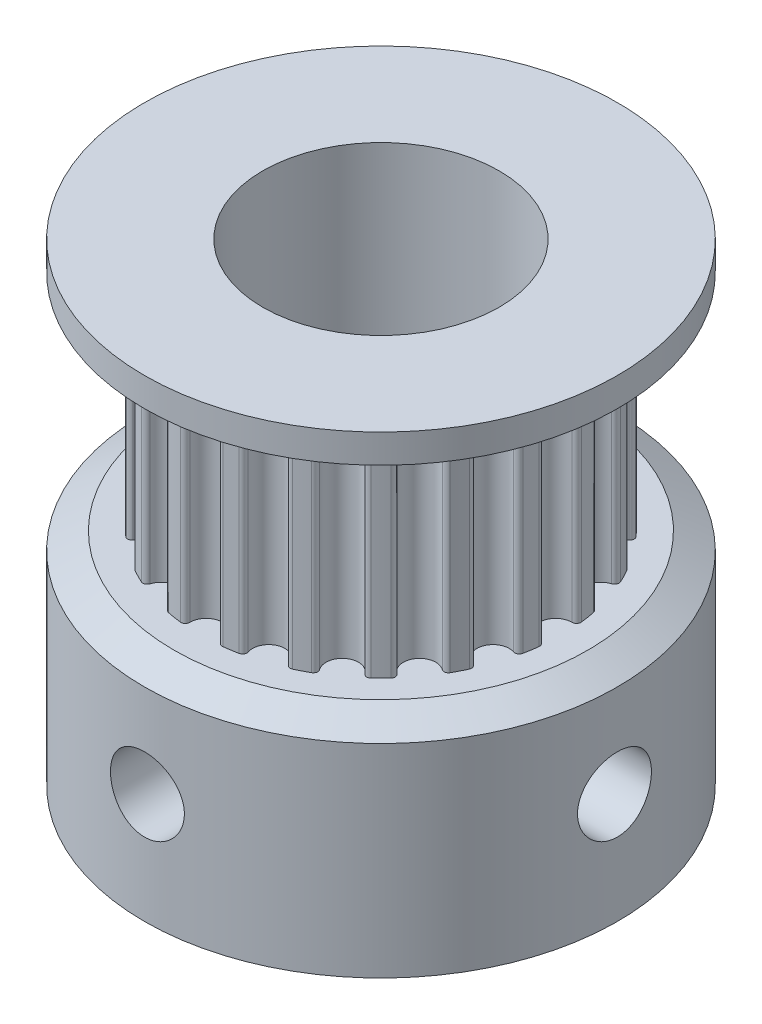
from build123d import *

# Parameters (mm, degrees)
SKETCH_1_R             = 8
SKETCH_1_R_2           = 4
EXTRUDE_1_DEPTH        = 7.45
SKETCH_2_R             = 4
EXTRUDE_2_DEPTH        = 7
SKETCH_3_R             = 8
SKETCH_3_R_2           = 4
EXTRUDE_3_DEPTH        = 1.55
CUT_EXTRUDE_1_REACH    = 10
SKETCH_4_R             = 1.25
CUT_EXTRUDE_2_REACH    = 10
SKETCH_5_R             = 1.25
CHAMFER_1_SIZE         = 1
CHAMFER_1_SIZE2        = 0.577350269
CHAMFER_1_PART_2_SIZE  = 1
CHAMFER_1_PART_2_SIZE2 = 0.577350269


with BuildPart() as part:
    # Эскиз1 → Бобышка-Вытянуть1 (new body)
    with BuildSketch(Plane(origin=(0, 0, 0), x_dir=(1, 0, 0), z_dir=(0, 1, 0))):
        Circle(SKETCH_1_R)
        Circle(SKETCH_1_R_2, mode=Mode.SUBTRACT)
    extrude(amount=EXTRUDE_1_DEPTH)

    # Эскиз2 → Бобышка-Вытянуть2 (add)
    with BuildSketch(Plane(origin=(0, 7.45, 0), x_dir=(1, 0, 0), z_dir=(0, 1, 0))):
        with BuildLine():
            ThreePointArc((-2.557469435, 5.549004423), (-2.773881953, 5.444049863), (-2.985996064, 5.3306592))
            ThreePointArc((-2.985996064, 5.3306592), (-3.059404709, 5.231014138), (-3.032930262, 5.110113057))
            ThreePointArc((-3.032930262, 5.110113057), (-3.150528952, 4.33633109), (-3.922779328, 4.463599867))
            ThreePointArc((-3.922779328, 4.463599867), (-4.029582035, 4.526139051), (-4.14703464, 4.487115298))
            ThreePointArc((-4.14703464, 4.487115298), (-4.320422433, 4.320422433), (-4.487115298, 4.14703464))
            ThreePointArc((-4.487115298, 4.14703464), (-4.526139051, 4.029582035), (-4.463599867, 3.922779328))
            ThreePointArc((-4.463599867, 3.922779328), (-4.33633109, 3.150528952), (-5.110113057, 3.032930262))
            ThreePointArc((-5.110113057, 3.032930262), (-5.231014138, 3.059404709), (-5.3306592, 2.985996064))
            ThreePointArc((-5.3306592, 2.985996064), (-5.444049863, 2.773881953), (-5.549004423, 2.557469435))
            ThreePointArc((-5.549004423, 2.557469435), (-5.549823367, 2.433706366), (-5.457341217, 2.351456627))
            ThreePointArc((-5.457341217, 2.351456627), (-5.097662927, 1.65633109), (-5.797233315, 1.305376312))
            ThreePointArc((-5.797233315, 1.305376312), (-5.92039813, 1.293194518), (-5.992481697, 1.19258673))
            ThreePointArc((-5.992481697, 1.19258673), (-6.034775761, 0.955814581), (-6.067718334, 0.717561302))
            ThreePointArc((-6.067718334, 0.717561302), (-6.030252304, 0.599602562), (-5.916879985, 0.549956967))
            ThreePointArc((-5.916879985, 0.549956967), (-5.36, 0), (-5.916879985, -0.549956967))
            ThreePointArc((-5.916879985, -0.549956967), (-6.030252304, -0.599602562), (-6.067718334, -0.717561302))
            ThreePointArc((-6.067718334, -0.717561302), (-6.034775761, -0.955814581), (-5.992481697, -1.19258673))
            ThreePointArc((-5.992481697, -1.19258673), (-5.92039813, -1.293194518), (-5.797233315, -1.305376312))
            ThreePointArc((-5.797233315, -1.305376312), (-5.097662927, -1.65633109), (-5.457341217, -2.351456627))
            ThreePointArc((-5.457341217, -2.351456627), (-5.549823367, -2.433706366), (-5.549004423, -2.557469435))
            ThreePointArc((-5.549004423, -2.557469435), (-5.444049863, -2.773881953), (-5.3306592, -2.985996064))
            ThreePointArc((-5.3306592, -2.985996064), (-5.231014138, -3.059404709), (-5.110113057, -3.032930262))
            ThreePointArc((-5.110113057, -3.032930262), (-4.33633109, -3.150528952), (-4.463599867, -3.922779328))
            ThreePointArc((-4.463599867, -3.922779328), (-4.526139051, -4.029582035), (-4.487115298, -4.14703464))
            ThreePointArc((-4.487115298, -4.14703464), (-4.320422433, -4.320422433), (-4.14703464, -4.487115298))
            ThreePointArc((-4.14703464, -4.487115298), (-4.029582035, -4.526139051), (-3.922779328, -4.463599867))
            ThreePointArc((-3.922779328, -4.463599867), (-3.150528952, -4.33633109), (-3.032930262, -5.110113057))
            ThreePointArc((-3.032930262, -5.110113057), (-3.059404709, -5.231014138), (-2.985996064, -5.3306592))
            ThreePointArc((-2.985996064, -5.3306592), (-2.773881953, -5.444049863), (-2.557469435, -5.549004423))
            ThreePointArc((-2.557469435, -5.549004423), (-2.433706366, -5.549823367), (-2.351456627, -5.457341217))
            ThreePointArc((-2.351456627, -5.457341217), (-1.65633109, -5.097662927), (-1.305376312, -5.797233315))
            ThreePointArc((-1.305376312, -5.797233315), (-1.293194518, -5.92039813), (-1.19258673, -5.992481697))
            ThreePointArc((-1.19258673, -5.992481697), (-0.955814581, -6.034775761), (-0.717561302, -6.067718334))
            ThreePointArc((-0.717561302, -6.067718334), (-0.599602562, -6.030252304), (-0.549956967, -5.916879985))
            ThreePointArc((-0.549956967, -5.916879985), (0, -5.36), (0.549956967, -5.916879985))
            ThreePointArc((0.549956967, -5.916879985), (0.599602562, -6.030252304), (0.717561302, -6.067718334))
            ThreePointArc((0.717561302, -6.067718334), (0.955814581, -6.034775761), (1.19258673, -5.992481697))
            ThreePointArc((1.19258673, -5.992481697), (1.293194518, -5.92039813), (1.305376312, -5.797233315))
            ThreePointArc((1.305376312, -5.797233315), (1.65633109, -5.097662927), (2.351456627, -5.457341217))
            ThreePointArc((2.351456627, -5.457341217), (2.433706366, -5.549823367), (2.557469435, -5.549004423))
            ThreePointArc((2.557469435, -5.549004423), (2.773881953, -5.444049863), (2.985996064, -5.3306592))
            ThreePointArc((2.985996064, -5.3306592), (3.059404709, -5.231014138), (3.032930262, -5.110113057))
            ThreePointArc((3.032930262, -5.110113057), (3.150528952, -4.33633109), (3.922779328, -4.463599867))
            ThreePointArc((3.922779328, -4.463599867), (4.029582035, -4.526139051), (4.14703464, -4.487115298))
            ThreePointArc((4.14703464, -4.487115298), (4.320422433, -4.320422433), (4.487115298, -4.14703464))
            ThreePointArc((4.487115298, -4.14703464), (4.526139051, -4.029582035), (4.463599867, -3.922779328))
            ThreePointArc((4.463599867, -3.922779328), (4.33633109, -3.150528952), (5.110113057, -3.032930262))
            ThreePointArc((5.110113057, -3.032930262), (5.231014138, -3.059404709), (5.3306592, -2.985996064))
            ThreePointArc((5.3306592, -2.985996064), (5.444049863, -2.773881953), (5.549004423, -2.557469435))
            ThreePointArc((5.549004423, -2.557469435), (5.549823367, -2.433706366), (5.457341217, -2.351456627))
            ThreePointArc((5.457341217, -2.351456627), (5.097662927, -1.65633109), (5.797233315, -1.305376312))
            ThreePointArc((5.797233315, -1.305376312), (5.92039813, -1.293194518), (5.992481697, -1.19258673))
            ThreePointArc((5.992481697, -1.19258673), (6.034775761, -0.955814581), (6.067718334, -0.717561302))
            ThreePointArc((6.067718334, -0.717561302), (6.030252304, -0.599602562), (5.916879985, -0.549956967))
            ThreePointArc((5.916879985, -0.549956967), (5.36, 0), (5.916879985, 0.549956967))
            ThreePointArc((5.916879985, 0.549956967), (6.030252304, 0.599602562), (6.067718334, 0.717561302))
            ThreePointArc((6.067718334, 0.717561302), (6.034775761, 0.955814581), (5.992481697, 1.19258673))
            ThreePointArc((5.992481697, 1.19258673), (5.92039813, 1.293194518), (5.797233315, 1.305376312))
            ThreePointArc((5.797233315, 1.305376312), (5.097662927, 1.65633109), (5.457341217, 2.351456627))
            ThreePointArc((5.457341217, 2.351456627), (5.549823367, 2.433706366), (5.549004423, 2.557469435))
            ThreePointArc((5.549004423, 2.557469435), (5.444049863, 2.773881953), (5.3306592, 2.985996064))
            ThreePointArc((5.3306592, 2.985996064), (5.231014138, 3.059404709), (5.110113057, 3.032930262))
            ThreePointArc((5.110113057, 3.032930262), (4.33633109, 3.150528952), (4.463599867, 3.922779328))
            ThreePointArc((4.463599867, 3.922779328), (4.526139051, 4.029582035), (4.487115298, 4.14703464))
            ThreePointArc((4.487115298, 4.14703464), (4.320422433, 4.320422433), (4.14703464, 4.487115298))
            ThreePointArc((4.14703464, 4.487115298), (4.029582035, 4.526139051), (3.922779328, 4.463599867))
            ThreePointArc((3.922779328, 4.463599867), (3.150528952, 4.33633109), (3.032930262, 5.110113057))
            ThreePointArc((3.032930262, 5.110113057), (3.059404709, 5.231014138), (2.985996064, 5.3306592))
            ThreePointArc((2.985996064, 5.3306592), (2.773881953, 5.444049863), (2.557469435, 5.549004423))
            ThreePointArc((2.557469435, 5.549004423), (2.433706366, 5.549823367), (2.351456627, 5.457341217))
            ThreePointArc((2.351456627, 5.457341217), (1.65633109, 5.097662927), (1.305376312, 5.797233315))
            ThreePointArc((1.305376312, 5.797233315), (1.293194518, 5.92039813), (1.19258673, 5.992481697))
            ThreePointArc((1.19258673, 5.992481697), (0.955814581, 6.034775761), (0.717561302, 6.067718334))
            ThreePointArc((0.717561302, 6.067718334), (0.599602562, 6.030252304), (0.549956967, 5.916879985))
            ThreePointArc((0.549956967, 5.916879985), (0, 5.36), (-0.549956967, 5.916879985))
            ThreePointArc((-0.549956967, 5.916879985), (-0.599602562, 6.030252304), (-0.717561302, 6.067718334))
            ThreePointArc((-0.717561302, 6.067718334), (-0.955814581, 6.034775761), (-1.19258673, 5.992481697))
            ThreePointArc((-1.19258673, 5.992481697), (-1.293194518, 5.92039813), (-1.305376312, 5.797233315))
            ThreePointArc((-1.305376312, 5.797233315), (-1.65633109, 5.097662927), (-2.351456627, 5.457341217))
            ThreePointArc((-2.351456627, 5.457341217), (-2.433706366, 5.549823367), (-2.557469435, 5.549004423))
        make_face()
        Circle(SKETCH_2_R, mode=Mode.SUBTRACT)
    extrude(amount=EXTRUDE_2_DEPTH)

    # Эскиз3 → Бобышка-Вытянуть3 (add)
    with BuildSketch(Plane(origin=(0, 14.45, 0), x_dir=(1, 0, 0), z_dir=(0, 1, 0))):
        Circle(SKETCH_3_R)
        Circle(SKETCH_3_R_2, mode=Mode.SUBTRACT)
    extrude(amount=EXTRUDE_3_DEPTH)

    # Эскиз4 → Вырез-Вытянуть1 (cut, up to next)
    with BuildSketch(Plane.XY, mode=Mode.PRIVATE) as cut_extrude_1_sk1:
        with Locations((0, 3.725)):
            Circle(SKETCH_4_R)
    cut_extrude_1_tool1 = extrude(cut_extrude_1_sk1.sketch, amount=CUT_EXTRUDE_1_REACH, mode=Mode.PRIVATE) & part.part
    add(cut_extrude_1_tool1.solids().sort_by_distance((0, 3.725, 0))[0], mode=Mode.SUBTRACT)

    # Эскиз5 → Вырез-Вытянуть2 (cut, up to next)
    with BuildSketch(Plane(origin=(0, 0, 0), x_dir=(0, 0, -1), z_dir=(1, 0, 0)), mode=Mode.PRIVATE) as cut_extrude_2_sk1:
        with Locations((0, 3.725)):
            Circle(SKETCH_5_R)
    cut_extrude_2_tool1 = extrude(cut_extrude_2_sk1.sketch, amount=CUT_EXTRUDE_2_REACH, mode=Mode.PRIVATE) & part.part
    add(cut_extrude_2_tool1.solids().sort_by_distance((0, 3.725, 0))[0], mode=Mode.SUBTRACT)

    # Фаска1
    chamfer_1_edges = [part.edges().sort_by_distance(p)[0] for p in [
        (-8, 14.45, 0),
    ]]
    chamfer_1_side = [part.faces().sort_by_distance(p)[0] for p in [
        (-7.77372583, 14.45, 0),
    ]]
    chamfer(chamfer_1_edges, length=CHAMFER_1_SIZE, length2=CHAMFER_1_SIZE2, reference=chamfer_1_side[0])

    # Фаска1 part 2
    chamfer_1_part_2_edges = [part.edges().sort_by_distance(p)[0] for p in [
        (-8, 7.45, 0),
    ]]
    chamfer_1_part_2_side = [part.faces().sort_by_distance(p)[0] for p in [
        (-7.77372583, 7.45, 0),
    ]]
    chamfer(chamfer_1_part_2_edges, length=CHAMFER_1_PART_2_SIZE, length2=CHAMFER_1_PART_2_SIZE2, reference=chamfer_1_part_2_side[0])


solid = part.part
